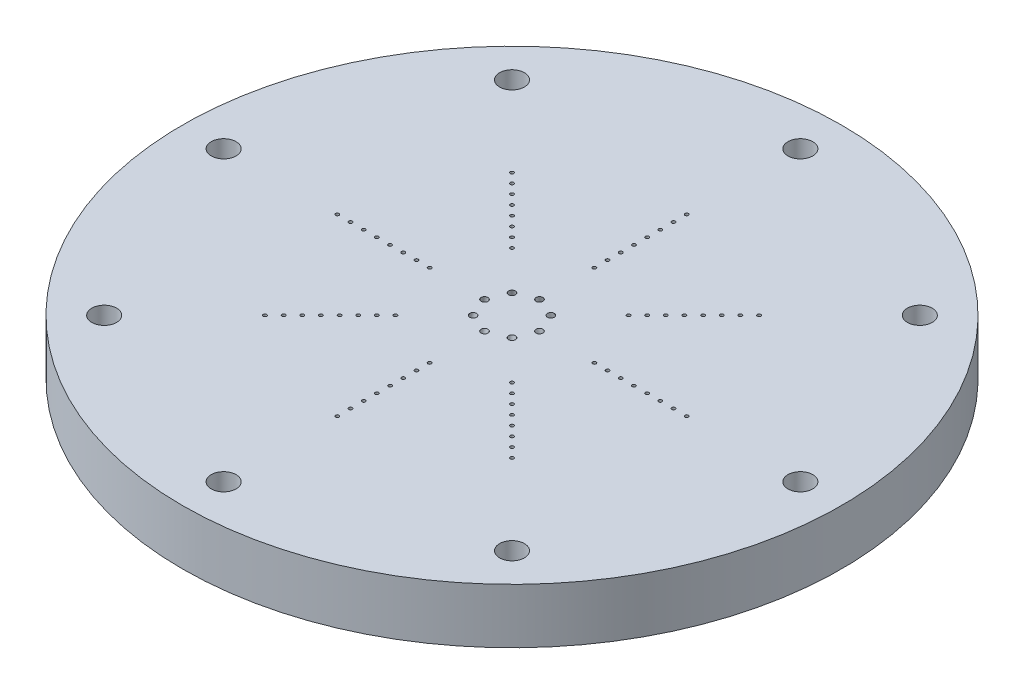
from build123d import *

# Parameters (mm, degrees)
SKETCH1_R                                      = 38.1
BOSS_EXTRUDE1_DEPTH                            = 6.35
CBORE_FOR_4_BUTTON_HEAD_CAP_SCREW1_D           = 2.8702
CBORE_FOR_4_BUTTON_HEAD_CAP_SCREW1_CBORE_D     = 4.826
CBORE_FOR_4_BUTTON_HEAD_CAP_SCREW1_CBORE_DEPTH = 1.905
CIRPATTERN1_COUNT                              = 8
SKETCH6_R                                      = 0.1984375
CUT_EXTRUDE1_DEPTH                             = 7.35
SKETCH7_R                                      = 0.396875
CIRPATTERN2_COUNT                              = 8


with BuildPart() as part:
    # Sketch1 → Boss-Extrude1 (new body)
    with BuildSketch(Plane(origin=(0, 0, 0), x_dir=(1, 0, 0), z_dir=(0, 1, 0))):
        Circle(SKETCH1_R)
    extrude(amount=BOSS_EXTRUDE1_DEPTH)

    # CBORE for #4 Button Head Cap Screw1 (through all)
    with Locations(Plane(origin=(0, 0, 0), x_dir=(-1, 0, 0), z_dir=(0, -1, 0))):
        with Locations((0, -33.3375)):
            cbore_for_4_button_head_cap_screw1 = CounterBoreHole(CBORE_FOR_4_BUTTON_HEAD_CAP_SCREW1_D / 2, CBORE_FOR_4_BUTTON_HEAD_CAP_SCREW1_CBORE_D / 2, CBORE_FOR_4_BUTTON_HEAD_CAP_SCREW1_CBORE_DEPTH)

    # CirPattern1: CBORE for #4 Button Head Cap Screw1 ×8 about axis
    cirpattern1_axis = Axis((0, 0, 0), (0, 1, 0))
    for i in range(1, CIRPATTERN1_COUNT):
        add(cbore_for_4_button_head_cap_screw1.rotate(cirpattern1_axis, i * 360 / CIRPATTERN1_COUNT), mode=Mode.SUBTRACT)

    # Sketch6 → Cut-Extrude1 (cut, through all)
    with BuildSketch(Plane(origin=(0, 6.35, 0), x_dir=(1, 0, 0), z_dir=(0, 1, 0))):
        with Locations((0, 9.525)):
            Circle(SKETCH6_R)
        with Locations((0, 11.049)):
            Circle(SKETCH6_R)
        with Locations((0, 12.573)):
            Circle(SKETCH6_R)
        with Locations((0, 14.097)):
            Circle(SKETCH6_R)
        with Locations((0, 15.621)):
            Circle(SKETCH6_R)
        with Locations((0, 17.145)):
            Circle(SKETCH6_R)
        with Locations((0, 18.669)):
            Circle(SKETCH6_R)
        with Locations((0, 20.193)):
            Circle(SKETCH6_R)
        with Locations((6.735192091, 6.735192091)):
            Circle(SKETCH6_R)
        with Locations((7.812822825, 7.812822825)):
            Circle(SKETCH6_R)
        with Locations((8.89045356, 8.89045356)):
            Circle(SKETCH6_R)
        with Locations((9.968084294, 9.968084294)):
            Circle(SKETCH6_R)
        with Locations((11.045715029, 11.045715029)):
            Circle(SKETCH6_R)
        with Locations((12.123345763, 12.123345763)):
            Circle(SKETCH6_R)
        with Locations((13.200976498, 13.200976498)):
            Circle(SKETCH6_R)
        with Locations((14.278607233, 14.278607233)):
            Circle(SKETCH6_R)
        with Locations((9.525, 0)):
            Circle(SKETCH6_R)
        with Locations((11.049, 0)):
            Circle(SKETCH6_R)
        with Locations((12.573, 0)):
            Circle(SKETCH6_R)
        with Locations((14.097, 0)):
            Circle(SKETCH6_R)
        with Locations((15.621, 0)):
            Circle(SKETCH6_R)
        with Locations((17.145, 0)):
            Circle(SKETCH6_R)
        with Locations((18.669, 0)):
            Circle(SKETCH6_R)
        with Locations((20.193, 0)):
            Circle(SKETCH6_R)
        with Locations((6.735192091, -6.735192091)):
            Circle(SKETCH6_R)
        with Locations((7.812822825, -7.812822825)):
            Circle(SKETCH6_R)
        with Locations((8.89045356, -8.89045356)):
            Circle(SKETCH6_R)
        with Locations((9.968084294, -9.968084294)):
            Circle(SKETCH6_R)
        with Locations((11.045715029, -11.045715029)):
            Circle(SKETCH6_R)
        with Locations((12.123345763, -12.123345763)):
            Circle(SKETCH6_R)
        with Locations((13.200976498, -13.200976498)):
            Circle(SKETCH6_R)
        with Locations((14.278607233, -14.278607232)):
            Circle(SKETCH6_R)
        with Locations((0, -9.525)):
            Circle(SKETCH6_R)
        with Locations((0, -11.049)):
            Circle(SKETCH6_R)
        with Locations((0, -12.573)):
            Circle(SKETCH6_R)
        with Locations((0, -14.097)):
            Circle(SKETCH6_R)
        with Locations((0, -15.621)):
            Circle(SKETCH6_R)
        with Locations((0, -17.145)):
            Circle(SKETCH6_R)
        with Locations((0, -18.669)):
            Circle(SKETCH6_R)
        with Locations((0, -20.193)):
            Circle(SKETCH6_R)
        with Locations((-6.735192091, -6.735192091)):
            Circle(SKETCH6_R)
        with Locations((-7.812822825, -7.812822825)):
            Circle(SKETCH6_R)
        with Locations((-8.89045356, -8.89045356)):
            Circle(SKETCH6_R)
        with Locations((-9.968084294, -9.968084294)):
            Circle(SKETCH6_R)
        with Locations((-11.045715029, -11.045715029)):
            Circle(SKETCH6_R)
        with Locations((-12.123345763, -12.123345763)):
            Circle(SKETCH6_R)
        with Locations((-13.200976498, -13.200976498)):
            Circle(SKETCH6_R)
        with Locations((-14.278607232, -14.278607233)):
            Circle(SKETCH6_R)
        with Locations((-9.525, 0)):
            Circle(SKETCH6_R)
        with Locations((-11.049, 0)):
            Circle(SKETCH6_R)
        with Locations((-12.573, 0)):
            Circle(SKETCH6_R)
        with Locations((-14.097, 0)):
            Circle(SKETCH6_R)
        with Locations((-15.621, 0)):
            Circle(SKETCH6_R)
        with Locations((-17.145, 0)):
            Circle(SKETCH6_R)
        with Locations((-18.669, 0)):
            Circle(SKETCH6_R)
        with Locations((-20.193, 0)):
            Circle(SKETCH6_R)
        with Locations((-6.735192091, 6.735192091)):
            Circle(SKETCH6_R)
        with Locations((-7.812822825, 7.812822825)):
            Circle(SKETCH6_R)
        with Locations((-8.89045356, 8.89045356)):
            Circle(SKETCH6_R)
        with Locations((-9.968084294, 9.968084294)):
            Circle(SKETCH6_R)
        with Locations((-11.045715029, 11.045715029)):
            Circle(SKETCH6_R)
        with Locations((-12.123345763, 12.123345763)):
            Circle(SKETCH6_R)
        with Locations((-13.200976498, 13.200976498)):
            Circle(SKETCH6_R)
        with Locations((-14.278607232, 14.278607232)):
            Circle(SKETCH6_R)
    extrude(amount=-CUT_EXTRUDE1_DEPTH, mode=Mode.SUBTRACT)

    # Cut-Sweep1: sweep along a curve in space
    with BuildLine() as cut_sweep1_path:
        Line((0, 6.35, -3.175), (0, 0, -4.7625))
    # Sketch7 → Cut-Sweep1 (sweep, cut)
    with BuildSketch(Plane(origin=(0, 6.35, 0), x_dir=(1, 0, 0), z_dir=(0, 1, 0))):
        with Locations((0, 3.175)):
            Circle(SKETCH7_R)
    cut_sweep1 = sweep(path=cut_sweep1_path.line, mode=Mode.SUBTRACT)

    # CirPattern2: Cut-Sweep1 ×8 about axis
    cirpattern2_axis = Axis((0, 6.35, 0), (0, 1, 0))
    for i in range(1, CIRPATTERN2_COUNT):
        add(cut_sweep1.rotate(cirpattern2_axis, i * 360 / CIRPATTERN2_COUNT), mode=Mode.SUBTRACT)


solid = part.part
